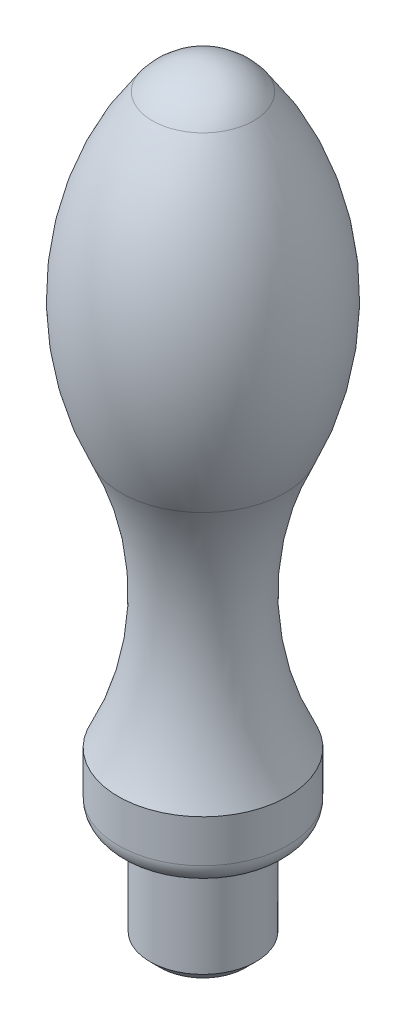
from build123d import *


with BuildPart() as part:
    # Sketch1 → Revolve1 (revolve)
    with BuildSketch(Plane.XY):
        with BuildLine():
            Line((0, 0), (4, 0))
            Line((4, 0), (5, 1))
            Line((5, 1), (5, 10))
            Line((5, 10), (6, 10))
            ThreePointArc((6, 10), (7.414213562, 10.585786438), (8, 12))
            Line((8, 12), (8, 16))
            ThreePointArc((8, 16), (5, 28.303061069), (7.726981853, 40.669502823))
            ThreePointArc((7.726981853, 40.669502823), (10.3121962, 55.557059673), (4.784815021, 69.620158175))
            ThreePointArc((4.784815021, 69.620158175), (2.671989048, 71.372194573), (0, 72))
            Line((0, 72), (0, 0))
        make_face()
    revolve(axis=Axis((0, -4.536906655, 0), (0, 1, 0)))


solid = part.part
